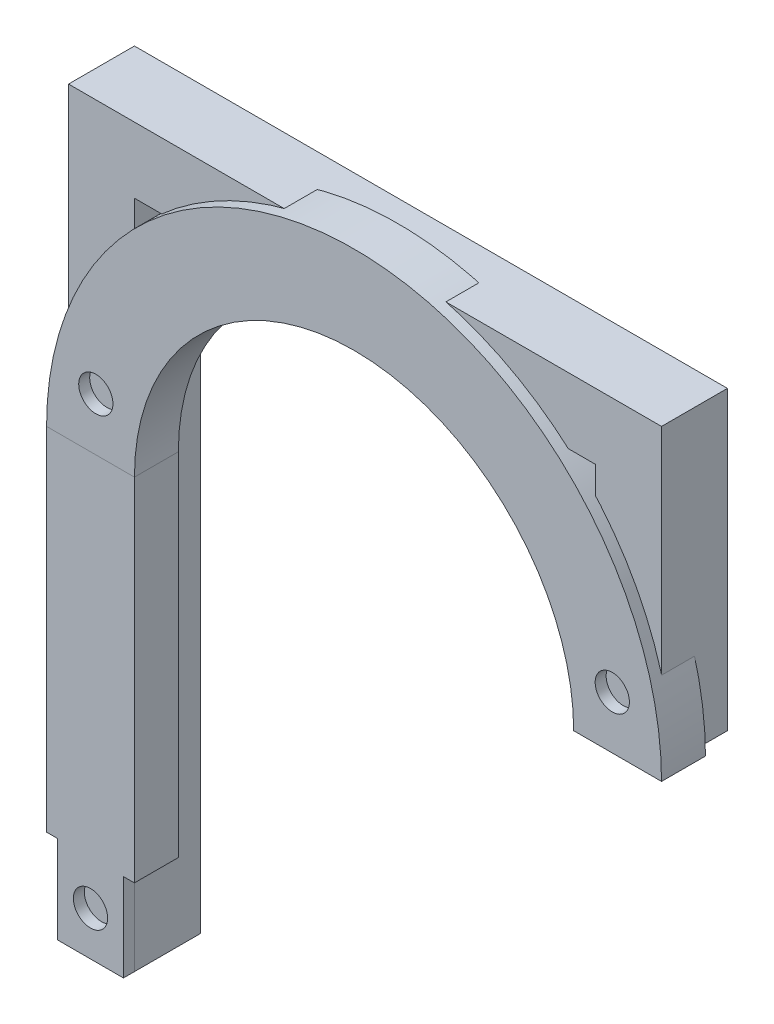
from build123d import *

# Parameters (mm, degrees)
EXTRUDE_THIN3_DEPTH = 4.7625
SKETCH38_W          = 12.7
SKETCH38_H          = 6.35
SKETCH39_R          = 2.4765
CUT_EXTRUDE1_DEPTH  = 7.35
SKETCH42_W          = 12.7
SKETCH42_H          = 6.35
CUT_EXTRUDE2_DEPTH  = 12.7
SKETCH43_W          = 9.525
SKETCH43_H          = 4.7625
BOSS_EXTRUDE4_DEPTH = 12.7
SKETCH44_R          = 2.4765
CUT_EXTRUDE3_DEPTH  = 12.1125


with BuildPart() as part:
    # Sketch8 → Extrude-Thin3 (new body, symmetric)
    with BuildSketch(Plane.XY):
        Polygon((4.7625, 0), (4.7625, 96.8375), (71.4375, 96.8375), (71.4375, 63.5), (80.9625, 63.5), (80.9625, 106.3625), (-4.7625, 106.3625), (-4.7625, 0), align=None)
    extrude(amount=EXTRUDE_THIN3_DEPTH, both=True)


with BuildPart() as body_2:
    # Sweep5: sweep along a path in Sketch37
    with BuildLine(Plane.XY) as sweep5_path:
        Line((0, 0), (0, 63.5))
        ThreePointArc((0, 63.5), (38.1, 101.6), (76.2, 63.5))
    # Sketch38 → Sweep5 (sweep)
    with BuildSketch(Plane(origin=(0, 0, 0), x_dir=(1, 0, 0), z_dir=(0, 1, 0))):
        with Locations((0, -3.175)):
            Rectangle(SKETCH38_W, SKETCH38_H)
    sweep(path=sweep5_path.line)

    # Sketch39 → Cut-Extrude1 (cut, through all)
    with BuildSketch(Plane.XY):
        with Locations((75.43022368, 71.12)):
            Circle(SKETCH39_R)
        with Locations((0.76977632, 71.12)):
            Circle(SKETCH39_R)
    extrude(amount=CUT_EXTRUDE1_DEPTH, mode=Mode.SUBTRACT)

    # Sketch42 → Cut-Extrude2 (cut)
    with BuildSketch(Plane.XZ):
        with Locations((0, 3.175)):
            Rectangle(SKETCH42_W, SKETCH42_H)
    extrude(amount=-CUT_EXTRUDE2_DEPTH, mode=Mode.SUBTRACT)

    # Sketch43 → Boss-Extrude4 (add)
    with BuildSketch(Plane.XZ.offset(-12.7)):
        with Locations((0, 3.96875)):
            Rectangle(SKETCH43_W, SKETCH43_H)
    extrude(amount=BOSS_EXTRUDE4_DEPTH)

    # Sketch44 → Cut-Extrude3 (cut, through all)
    with BuildSketch(Plane.XY.offset(6.35)):
        with Locations((0, 6.35)):
            Circle(SKETCH44_R)
    extrude(amount=-CUT_EXTRUDE3_DEPTH, mode=Mode.SUBTRACT)


solid = Compound([part.part, body_2.part])
